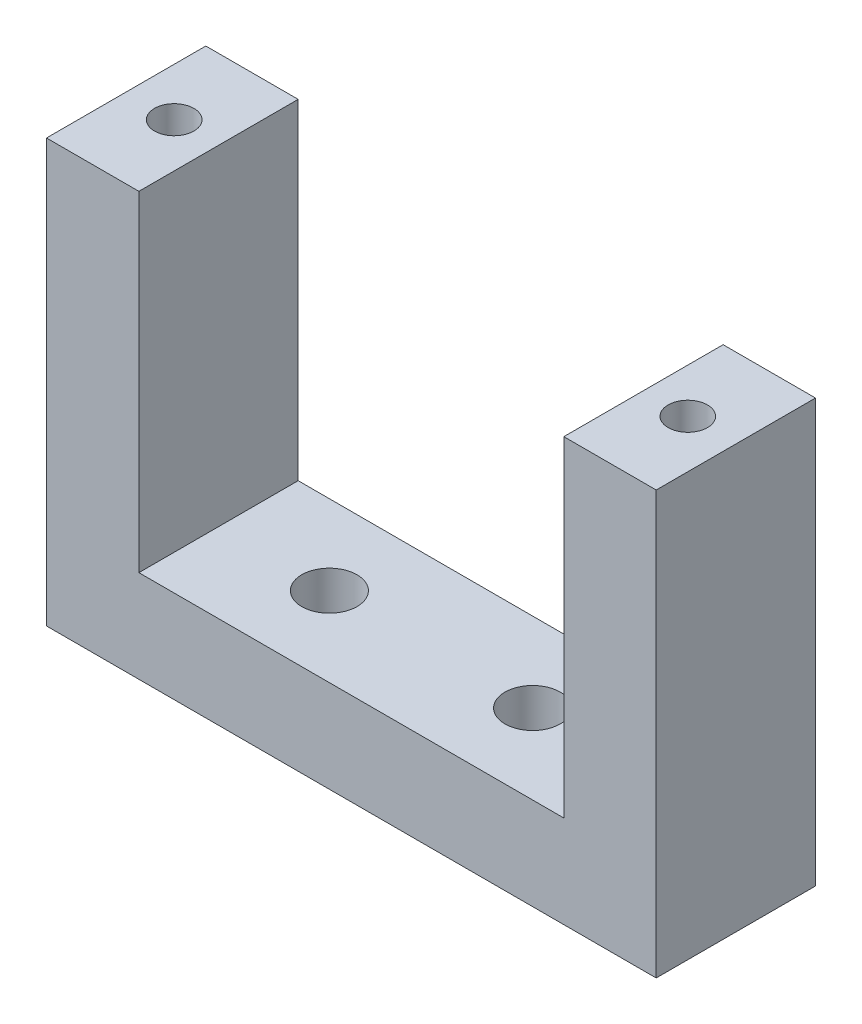
from build123d import *

# Parameters (mm, degrees)
BOSS_EXTRUDE1_DEPTH       = 10.95
F_6_CLEARANCE_HOLE1_D     = 3.7973
F_6_32_TAPPED_HOLE1_D     = 2.7051
F_6_32_TAPPED_HOLE1_DEPTH = 9.398
F_6_32_TAPPED_HOLE1_TIP   = 0.81269403


with BuildPart() as part:
    # Sketch1 → Boss-Extrude1 (new body)
    with BuildSketch(Plane.XY):
        Polygon((-20.955, 22.701840042), (-14.605, 22.701840042), (-14.605, 0), (14.605, 0), (14.605, 22.701840042), (20.955, 22.701840042), (20.955, -6.35), (-20.955, -6.35), align=None)
    extrude(amount=BOSS_EXTRUDE1_DEPTH)

    # #6 Clearance Hole1 (through all)
    with Locations(Plane(origin=(0, -6.35, 0), x_dir=(-1, 0, 0), z_dir=(0, -1, 0))):
        with Locations((-6.985, -5.475), (6.985, -5.475)):
            Hole(F_6_CLEARANCE_HOLE1_D / 2)

    # #6-32 Tapped Hole1
    with Locations(Plane(origin=(0, 22.701840042, 0), x_dir=(1, 0, 0), z_dir=(0, 1, 0))):
        with Locations((17.653, -5.475), (-17.653, -5.475)):
            Hole(F_6_32_TAPPED_HOLE1_D / 2, depth=F_6_32_TAPPED_HOLE1_DEPTH)
            with Locations((0, 0, -(F_6_32_TAPPED_HOLE1_DEPTH + F_6_32_TAPPED_HOLE1_TIP / 2))):  # 118° drill point
                Cone(0, F_6_32_TAPPED_HOLE1_D / 2, F_6_32_TAPPED_HOLE1_TIP, mode=Mode.SUBTRACT)


solid = part.part
